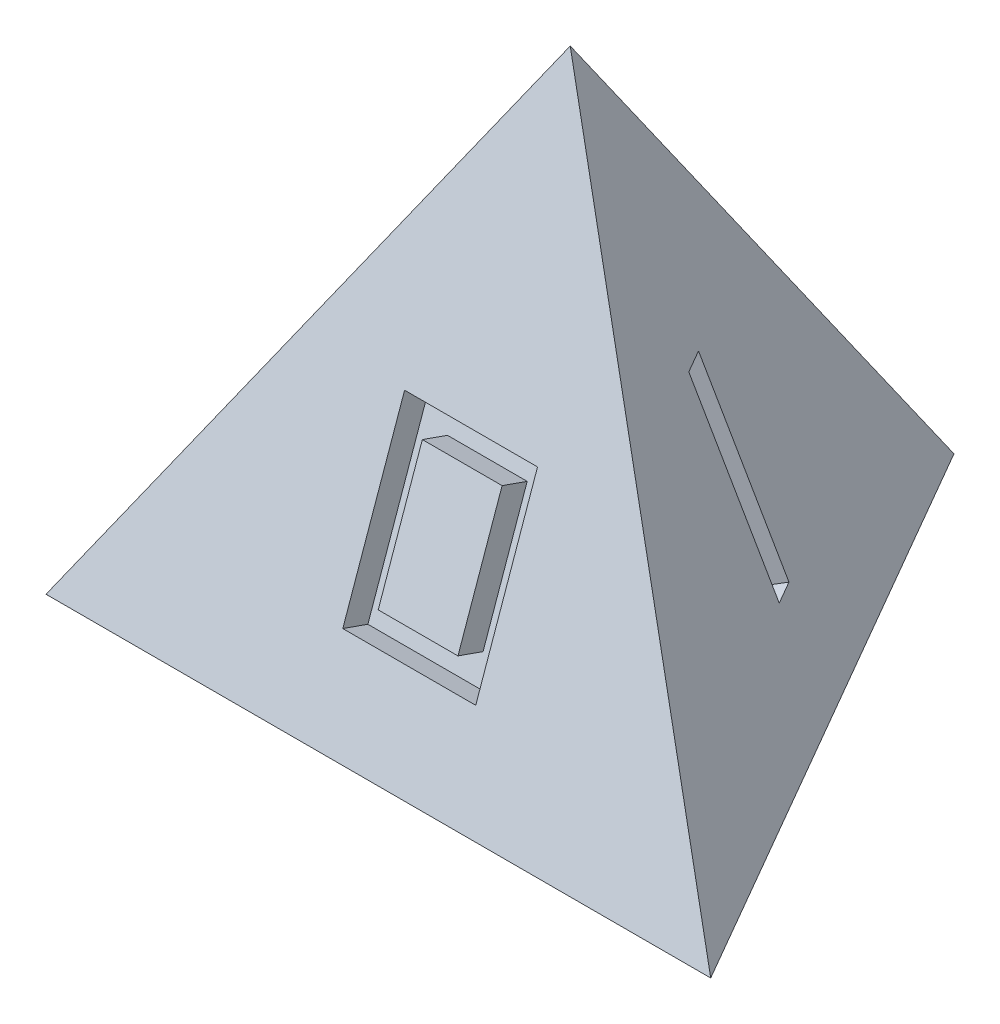
from build123d import *

# Parameters (mm, degrees)
SKETCH4_W               = 2.54
SKETCH4_H               = 3.556
SKETCH4_W_2             = 1.524
SKETCH4_H_2             = 2.54
CUT_EXTRUDE1_DEPTH      = 0.508
CUT_EXTRUDE2_DEPTH      = 0.508
CUT_EXTRUDE3_DEPTH      = 0.508
CUT_EXTRUDE4_DEPTH      = 15.231557685
CUT_EXTRUDE4_DEPTH_BACK = 0.508
SKETCH8_W               = 0.762
SKETCH8_H               = 0.254
SKETCH8_W_2             = 1.016
SKETCH8_W_3             = 0.254


with BuildPart() as part:
    # Sketch1 → Loft1 section 0
    with BuildSketch(Plane(origin=(0, 0, 0), x_dir=(1, 0, 0), z_dir=(0, 1, 0)), mode=Mode.PRIVATE) as loft1_s0:
        with BuildLine():
            Line((0, 7.332348419), (-6.35, -3.666174209))
            Line((-6.35, -3.666174209), (6.35, -3.666174209))
            Line((6.35, -3.666174209), (0, 7.332348419))
        make_face()
    loft([Vertex(0, 10.414, 0), loft1_s0.sketch])

    # Sketch4 → Cut-Extrude1 (cut)
    with BuildSketch(Plane(origin=(0, 1.148332745, 3.26191188), x_dir=(1, 0, 0), z_dir=(6.377659034928701e-15, 0.3320665177261577, 0.9432559715184545))):
        with Locations((0, 2.338586297)):
            Rectangle(SKETCH4_W, SKETCH4_H)
        with Locations((0, 2.338586297)):
            Rectangle(SKETCH4_W_2, SKETCH4_H_2, mode=Mode.SUBTRACT)
    extrude(amount=-CUT_EXTRUDE1_DEPTH, mode=Mode.SUBTRACT)

    # Sketch6 → Cut-Extrude2 (cut)
    with BuildSketch(Plane(origin=(2.824898553, 1.148332745, -1.63095594), x_dir=(-0.43690884833145366, -0.17760522289896655, -0.881797620233062), z_dir=(0.8168836336063493, 0.3320665177261613, -0.4716279857592303))):
        Polygon((-0.621304332, 4.589694472), (-1.120218022, 4.494043391), (-0.402834916, 0.752190711), (0.096078775, 0.847841792), align=None)
    extrude(amount=-CUT_EXTRUDE2_DEPTH, mode=Mode.SUBTRACT)

    # Sketch7 → Cut-Extrude3 (cut)
    with BuildSketch(Plane(origin=(-2.824898553, 1.148332745, -1.63095594), x_dir=(-0.43690884833145016, 0.17760522289896233, 0.8817976202330645), z_dir=(-0.8168836336063534, 0.33206651772615786, -0.47162798575922543))):
        Polygon((1.974568782, 3.554370693), (-0.270542826, 3.984800557), (-0.366193906, 3.485886867), (1.380004011, 3.151108083), (1.23652739, 2.402737547), (-0.759127373, 2.785341871), (-1.093906156, 1.039143954), (1.151205452, 0.60871409), (1.246856533, 1.10762778), (-0.499341385, 1.442406563), (-0.355864763, 2.190777099), (1.639789999, 1.808172776), align=None)
    extrude(amount=-CUT_EXTRUDE3_DEPTH, mode=Mode.SUBTRACT)

    # Sketch8 → Cut-Extrude4 (cut, two sides: drawn at the far end of the back side and taken through both)
    with BuildSketch(Plane.XZ.offset(-CUT_EXTRUDE4_DEPTH_BACK)):
        Polygon((0, 1.126174209), (-1.016, 1.126174209), (-1.016, 0.110174209), (-0.762, 0.110174209), (-0.762, 0.872174209), (0, 0.872174209), align=None)
        Polygon((-1.016, 0.110174209), (-1.016, 1.126174209), (0, 1.126174209), (0, 1.380174209), (-1.27, 1.380174209), (-1.27, -1.667825791), (0, -1.667825791), (0, -1.413825791), (-1.016, -1.413825791), (-1.016, -0.397825791), (-1.016, -0.143825791), align=None)
        with Locations((-0.381, -0.016825791)):
            Rectangle(SKETCH8_W, SKETCH8_H)
        with Locations((-0.381, -0.270825791)):
            Rectangle(SKETCH8_W, SKETCH8_H)
        with Locations((0.508, -0.016825791)):
            Rectangle(SKETCH8_W_2, SKETCH8_H)
        with Locations((0.508, -0.270825791)):
            Rectangle(SKETCH8_W_2, SKETCH8_H)
        with Locations((-0.889, -0.016825791)):
            Rectangle(SKETCH8_W_3, SKETCH8_H)
        with Locations((-0.889, -0.270825791)):
            Rectangle(SKETCH8_W_3, SKETCH8_H)
        Polygon((-0.762, -0.397825791), (-1.016, -0.397825791), (-1.016, -1.413825791), (0, -1.413825791), (0, -1.159825791), (-0.762, -1.159825791), align=None)
        with Locations((0.508, -1.286825791)):
            Rectangle(SKETCH8_W_2, SKETCH8_H)
        with Locations((0.508, -1.540825791)):
            Rectangle(SKETCH8_W_2, SKETCH8_H)
        with Locations((0.508, 0.999174209)):
            Rectangle(SKETCH8_W_2, SKETCH8_H)
        with Locations((0.508, 1.253174209)):
            Rectangle(SKETCH8_W_2, SKETCH8_H)
    extrude(amount=CUT_EXTRUDE4_DEPTH + CUT_EXTRUDE4_DEPTH_BACK, mode=Mode.SUBTRACT)


solid = part.part
